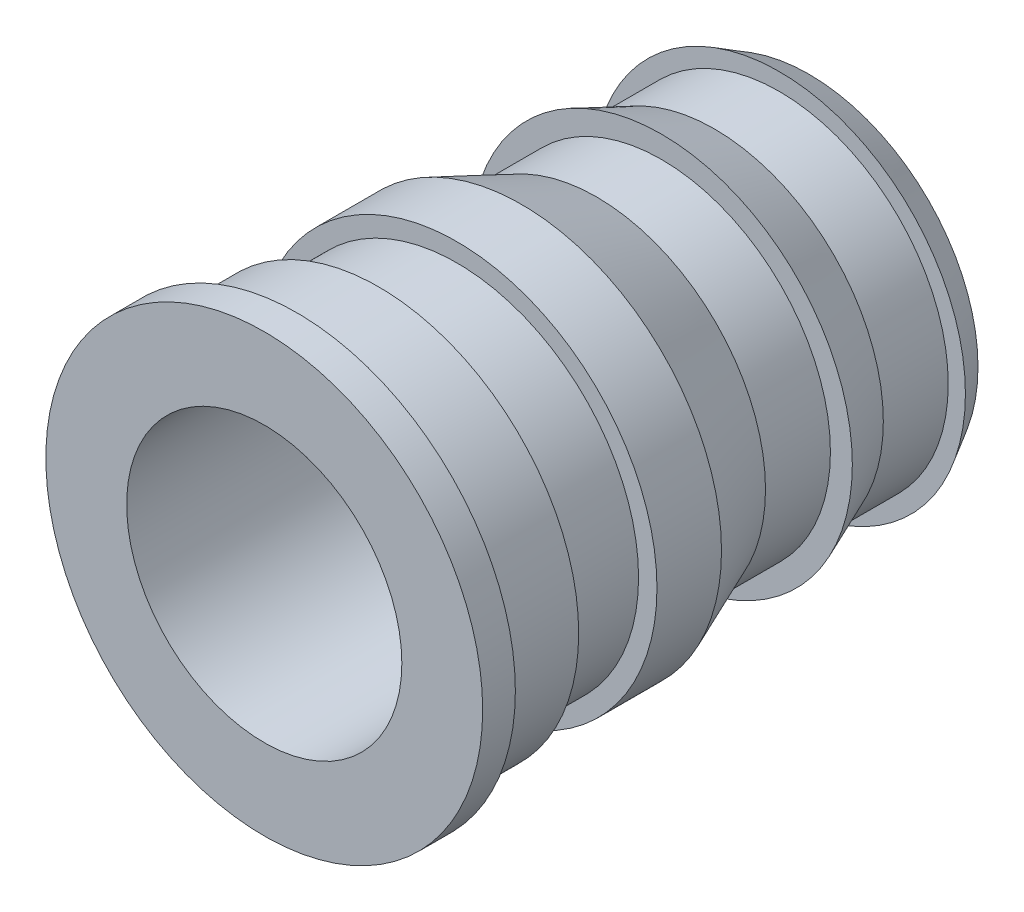
from build123d import *


with BuildPart() as part:
    # Sketch3 → Revolve1 (revolve)
    with BuildSketch(Plane(origin=(0, 0, 0), x_dir=(0, 0, -1), z_dir=(1, 0, 0))):
        Polygon((-3.96, 2), (-3.96, 3.175), (-3.4848, 3.175), (-3.4848, 2.9075), (-2.2968, 2.9075), (-2.2968, 2.64), (-1.158946666, 2.64), (-1.158946666, 2.9075), (-0.220748794, 2.9075), (0.8712, 2.4552), (1.814742989, 2.4552), (1.814742989, 2.77375), (2.583790719, 2.4552), (3.527333708, 2.4552), (3.527333708, 2.705), (3.96, 2.4552), (3.96, 2), align=None)
    revolve(axis=Axis((0, 0, 3.96), (0, 0, -1)))


solid = part.part
